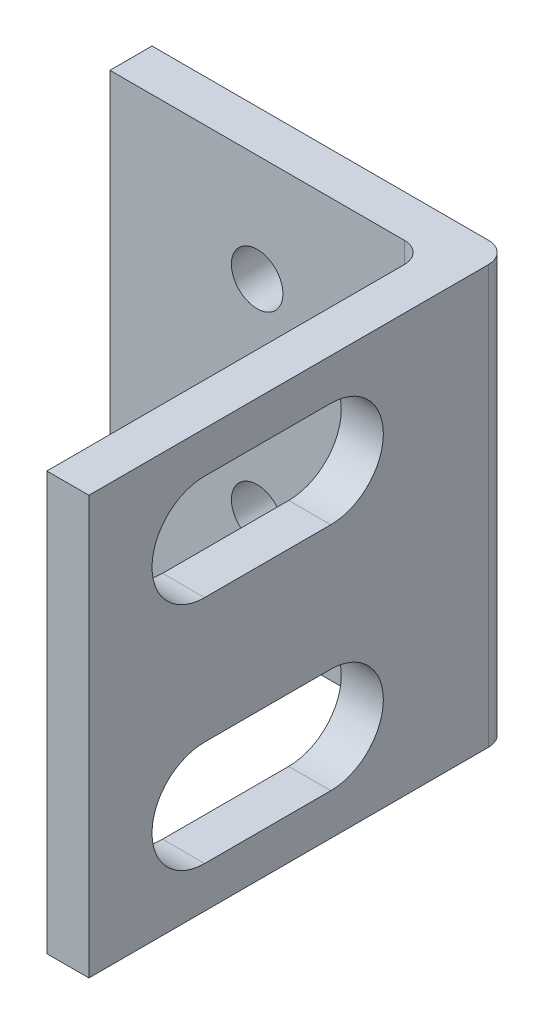
from build123d import *

# Parameters (mm, degrees)
BOSS_EXTRUDE1_DEPTH = 19.88
SKETCH3_R           = 1.225
CUT_EXTRUDE1_DEPTH  = 3
CUT_EXTRUDE3_DEPTH  = 3


with BuildPart() as part:
    # Sketch1 → Boss-Extrude1 (new body)
    with BuildSketch(Plane(origin=(0, 0, 0), x_dir=(1, 0, 0), z_dir=(0, 1, 0))):
        with BuildLine():
            Line((-0.688375332, 9.340054497), (-0.688375332, -7.659945503))
            Line((-0.688375332, -7.659945503), (1.311624668, -7.659945503))
            Line((1.311624668, -7.659945503), (1.311624668, 11.340054497))
            ThreePointArc((1.311624668, 11.340054497), (1.018731449, 12.047161278), (0.311624668, 12.340054497))
            Line((0.311624668, 12.340054497), (-15.688375332, 12.340054497))
            Line((-15.688375332, 12.340054497), (-15.688375332, 10.340054497))
            Line((-15.688375332, 10.340054497), (-1.688375332, 10.340054497))
            ThreePointArc((-1.688375332, 10.340054497), (-0.981268551, 10.047161278), (-0.688375332, 9.340054497))
        make_face()
    extrude(amount=BOSS_EXTRUDE1_DEPTH)

    # Sketch3 → Cut-Extrude1 (cut, through all)
    with BuildSketch(Plane.XY.offset(-10.340054497)):
        with Locations((-8.688375332, 5.095)):
            Circle(SKETCH3_R)
        with Locations((-8.688375332, 14.785)):
            Circle(SKETCH3_R)
    extrude(amount=-CUT_EXTRUDE1_DEPTH, mode=Mode.SUBTRACT)

    # Sketch4 → Cut-Extrude3 (cut, through all)
    with BuildSketch(Plane.ZY.offset(0.688375332)):
        with BuildLine():
            Line((2.159945503, 17.915386938), (-3.840054497, 17.915386938))
            ThreePointArc((-3.840054497, 17.915386938), (-6.340054497, 15.415386938), (-3.840054497, 12.915386938))
            Line((-3.840054497, 12.915386938), (2.159945503, 12.915386938))
            ThreePointArc((2.159945503, 12.915386938), (4.659945503, 15.415386938), (2.159945503, 17.915386938))
        make_face()
        with BuildLine():
            Line((2.159945503, 6.964613062), (-3.840054497, 6.964613062))
            ThreePointArc((-3.840054497, 6.964613062), (-6.340054497, 4.464613062), (-3.840054497, 1.964613062))
            Line((-3.840054497, 1.964613062), (2.159945503, 1.964613062))
            ThreePointArc((2.159945503, 1.964613062), (4.659945503, 4.464613062), (2.159945503, 6.964613062))
        make_face()
    extrude(amount=-CUT_EXTRUDE3_DEPTH, mode=Mode.SUBTRACT)


solid = part.part
